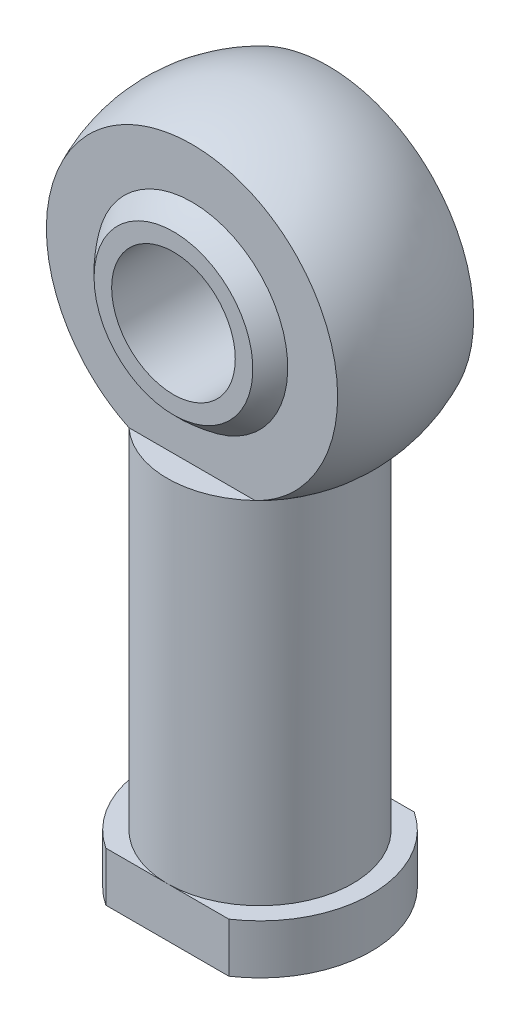
from build123d import *

# Parameters (mm, degrees)
CUT_EXTRUDE3_DEPTH      = 59.940648113
CUT_EXTRUDE3_DEPTH_BACK = 59.940648113
SKETCH3_W               = 17.579289035
SKETCH3_H               = 30.509322749
CUT_EXTRUDE4_DEPTH      = 59.268773799
CUT_EXTRUDE4_DEPTH_BACK = 59.268773799
SKETCH4_W               = 14.932737824
SKETCH4_H               = 19.875765969
CUT_EXTRUDE5_DEPTH      = 60.674114991
CUT_EXTRUDE5_DEPTH_BACK = 60.674114991
SKETCH5_R               = 5
CUT_EXTRUDE6_DEPTH      = 59.189346104
CUT_EXTRUDE6_DEPTH_BACK = 59.189346104
SKETCH6_W               = 15.994671042
SKETCH6_H               = 5.292782054
CUT_EXTRUDE7_DEPTH      = 58.976288256
CUT_EXTRUDE7_DEPTH_BACK = 25
SKETCH7_R               = 5


with BuildPart() as part:
    # Sketch1 → Revolve5 (revolve)
    with BuildSketch(Plane.XY):
        with BuildLine():
            Line((0, 52.5), (0, 53.5))
            ThreePointArc((0, 53.5), (-10.5, 43), (0, 32.5))
            Line((0, 32.5), (0, 33.5))
            ThreePointArc((0, 33.5), (-9.5, 43), (0, 52.5))
        make_face()
    revolve(axis=Axis((0, 0, 0), (0, 1, 0)))

    # Sketch1_7 → Revolve6 (revolve)
    with BuildSketch(Plane.XY):
        with BuildLine():
            Line((-7.5, 32.381619709), (-7.5, 4))
            Line((-7.5, 4), (-9, 4))
            Line((-9, 4), (-9, 0))
            Line((-9, 0), (0, 0))
            Line((0, 0), (0, 32.5))
            ThreePointArc((0, 32.5), (-10.5, 43), (0, 53.5))
            Line((0, 53.5), (0, 56))
            ThreePointArc((0, 56), (-12.39029749, 46.934530227), (-7.5, 32.381619709))
        make_face()
    revolve(axis=Axis((0, 0, 0), (0, 1, 0)))

    # Sketch3 → Cut-Extrude3 (cut, two sides: drawn at the far end of the back side and taken through both)
    with BuildSketch(Plane(origin=(0, 0, 0), x_dir=(0, 0, -1), z_dir=(1, 0, 0)).offset(-CUT_EXTRUDE3_DEPTH_BACK)):
        with Locations((-14.289644518, 47.636281084)):
            Rectangle(SKETCH3_W, SKETCH3_H)
        with Locations((14.289644518, 47.636281084)):
            Rectangle(SKETCH3_W, SKETCH3_H)
    extrude(amount=CUT_EXTRUDE3_DEPTH + CUT_EXTRUDE3_DEPTH_BACK, mode=Mode.SUBTRACT)

    # Sketch1_8 → Revolve7 (revolve)
    with BuildSketch(Plane.XY):
        with BuildLine():
            Line((0, 33.5), (0, 52.5))
            ThreePointArc((0, 52.5), (-9.5, 43), (0, 33.5))
        make_face()
    revolve(axis=Axis((0, 0, 0), (0, 1, 0)))

    # Sketch4 → Cut-Extrude4 (cut, two sides: drawn at the far end of the back side and taken through both)
    with BuildSketch(Plane(origin=(0, 0, 0), x_dir=(0, 0, -1), z_dir=(1, 0, 0)).offset(-CUT_EXTRUDE4_DEPTH_BACK)):
        with Locations((-14.466368912, 45.402031304)):
            Rectangle(SKETCH4_W, SKETCH4_H)
        with Locations((14.466368912, 45.402031304)):
            Rectangle(SKETCH4_W, SKETCH4_H)
    extrude(amount=CUT_EXTRUDE4_DEPTH + CUT_EXTRUDE4_DEPTH_BACK, mode=Mode.SUBTRACT)

    # Sketch5 → Cut-Extrude5 (cut, two sides: drawn at the far end of the back side and taken through both)
    with BuildSketch(Plane.XY.offset(7).offset(-CUT_EXTRUDE5_DEPTH_BACK)):
        with Locations((0, 43)):
            Circle(SKETCH5_R)
    extrude(amount=CUT_EXTRUDE5_DEPTH + CUT_EXTRUDE5_DEPTH_BACK, mode=Mode.SUBTRACT)

    # Sketch6 → Cut-Extrude6 (cut, two sides: drawn at the far end of the back side and taken through both)
    with BuildSketch(Plane(origin=(0, 0, 0), x_dir=(1, 0, 0), z_dir=(0, 1, 0)).offset(-CUT_EXTRUDE6_DEPTH_BACK)):
        with Locations((0.436218301, 10.146391027)):
            Rectangle(SKETCH6_W, SKETCH6_H)
        with Locations((0.436218301, -10.146391027)):
            Rectangle(SKETCH6_W, SKETCH6_H)
    extrude(amount=CUT_EXTRUDE6_DEPTH + CUT_EXTRUDE6_DEPTH_BACK, mode=Mode.SUBTRACT)

    # Sketch7 → Cut-Extrude7 (cut, two sides: drawn at the far end of the back side and taken through both)
    with BuildSketch(Plane.XZ.offset(-CUT_EXTRUDE7_DEPTH_BACK)):
        Circle(SKETCH7_R)
    extrude(amount=CUT_EXTRUDE7_DEPTH + CUT_EXTRUDE7_DEPTH_BACK, mode=Mode.SUBTRACT)


solid = part.part
